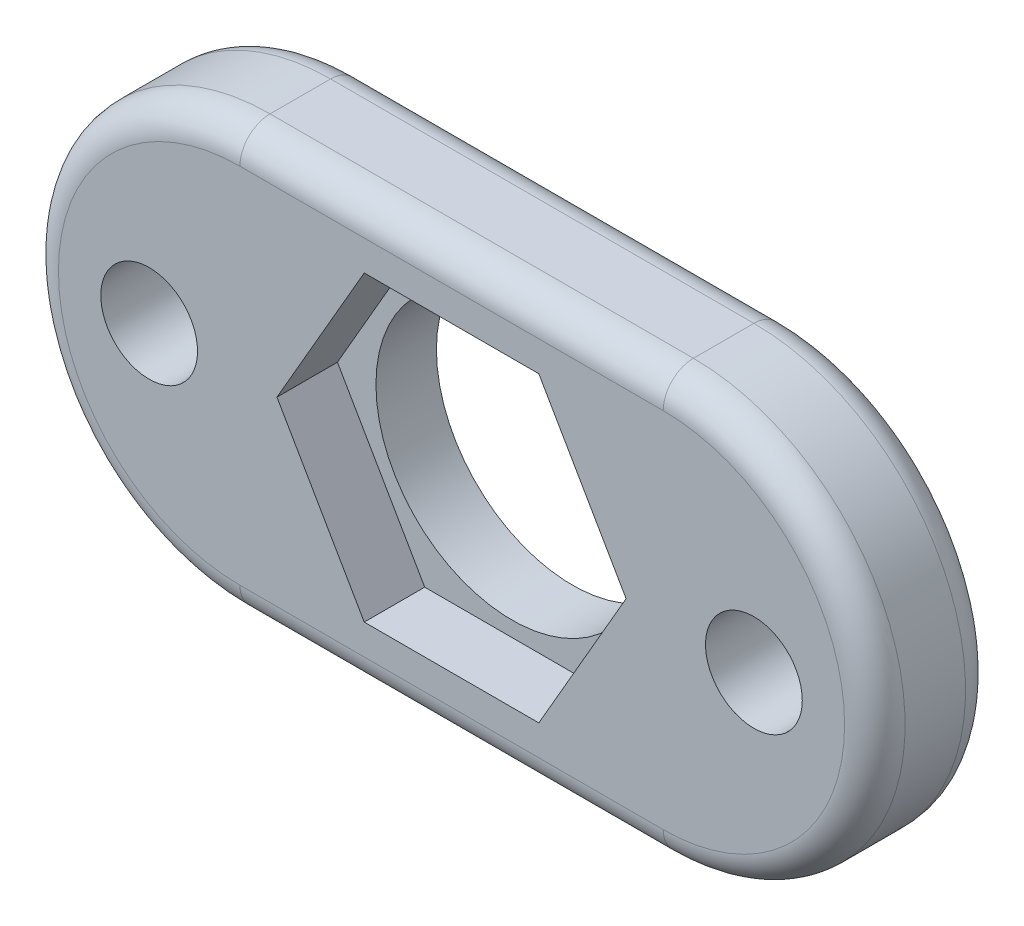
from build123d import *

# Parameters (mm, degrees)
BOSS_EXTRU_1_DEPTH      = 4
ESQUISSE3_R             = 4.5
ESQUISSE3_R_2           = 1.6
ENL_V_MAT_EXTRU_1_DEPTH = 5
ENL_V_MAT_EXTRU_2_DEPTH = 2
CONG_1_R                = 1


with BuildPart() as part:
    # Esquisse1 → Boss.-Extru.1 (new body)
    with BuildSketch(Plane.XY):
        with BuildLine():
            Line((-27.254178511, 7), (-13.254178511, 7))
            ThreePointArc((-13.254178511, 7), (-6.254178511, 0), (-13.254178511, -7))
            Line((-13.254178511, -7), (-27.254178511, -7))
            ThreePointArc((-27.254178511, -7), (-34.254178511, 0), (-27.254178511, 7))
        make_face()
    extrude(amount=BOSS_EXTRU_1_DEPTH)

    # Esquisse3 → Enlèv. mat.-Extru.1 (cut, through all)
    with BuildSketch(Plane.XY.offset(4)):
        with Locations((-20.254178511, 0)):
            Circle(ESQUISSE3_R)
        with Locations((-30.254178511, 0)):
            Circle(ESQUISSE3_R_2)
        with Locations((-10.254178511, 0)):
            Circle(ESQUISSE3_R_2)
    extrude(amount=-ENL_V_MAT_EXTRU_1_DEPTH, mode=Mode.SUBTRACT)

    # Esquisse4 → Enlèv. mat.-Extru.2 (cut)
    with BuildSketch(Plane.XY.offset(4)):
        Polygon((-23.140929857, 5), (-26.027681203, 0), (-23.140929857, -5), (-17.367427165, -5), (-14.480675819, 0), (-17.367427165, 5), align=None)
    extrude(amount=-ENL_V_MAT_EXTRU_2_DEPTH, mode=Mode.SUBTRACT)

    # Congé1
    cong_1_edges = [part.edges().sort_by_distance(p)[0] for p in [
        (-6.254178511, 0, 4),
        (-20.254178511, 7, 4),
        (-34.254178511, 0, 4),
        (-20.254178511, 7, 0),
        (-6.254178511, 0, 0),
        (-20.254178511, -7, 0),
        (-34.254178511, 0, 0),
        (-20.254178511, -7, 4),
    ]]
    fillet(cong_1_edges, radius=CONG_1_R)


solid = part.part
